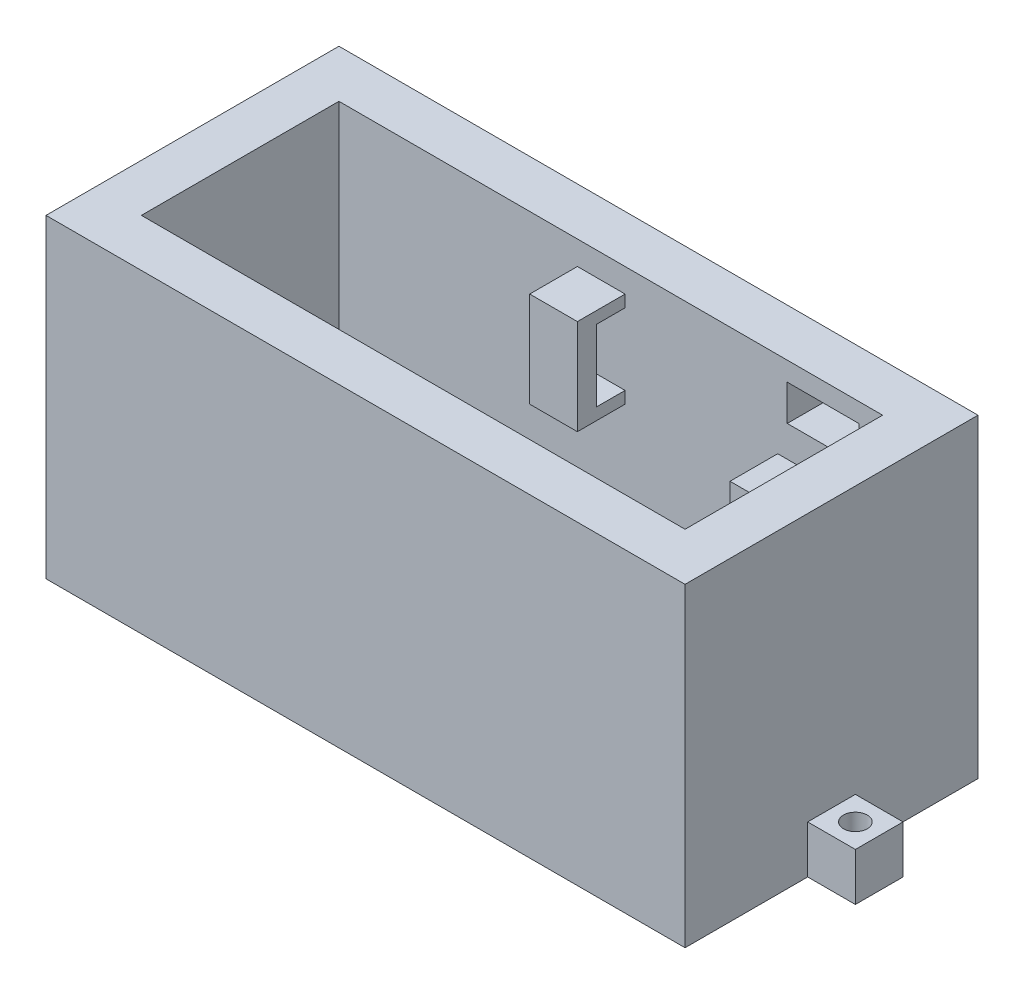
from build123d import *

# Parameters (mm, degrees)
SKETCH1_W                 = 72.39
SKETCH1_H                 = 26.30542054
BOSS_EXTRUDE1_DEPTH       = 35.56
SKETCH1_3_W               = 85.09
SKETCH1_3_H               = 39.00542054
SKETCH1_3_R               = 1.967283446
SKETCH1_3_W_2             = 3.175
SKETCH1_3_H_2             = 3.175
SKETCH1_3_R_2             = 1.397
BOSS_EXTRUDE2_DEPTH       = 6.35
SKETCH1_4_W               = 6.35
SKETCH1_4_H               = 6.35
SKETCH1_4_R               = 1.5875
BOSS_EXTRUDE3_DEPTH       = 6.35
SKETCH1_5_R               = 1.967283446
BOSS_EXTRUDE4_DEPTH       = 2.54
SKETCH2_W                 = 6.35
SKETCH2_H                 = 12.7
BOSS_EXTRUDE8_DEPTH       = 6.35
SKETCH2_4_W               = 6.35
SKETCH2_4_H               = 9.525
CUT_EXTRUDE1_DEPTH        = 3.81
SKETCH1_10_R              = 1.905
SKETCH1_10_R_2            = 1.397
SKETCH1_10_R_3            = 1.967283446
CUT_EXTRUDE4_DEPTH        = 98.832500687
BOSS_EXTRUDE11_DEPTH      = 2.54
BOSS_EXTRUDE11_DEPTH_BACK = 6.35
SKETCH1_11_W              = 3.175
SKETCH1_11_H              = 3.175
SKETCH6_W                 = 6.35
SKETCH6_H                 = 12.7
BOSS_EXTRUDE12_DEPTH      = 6.35
SKETCH6_8_W               = 6.35
SKETCH6_8_H               = 9.525
CUT_EXTRUDE5_DEPTH        = 3.81
SKETCH8_W                 = 9.525
SKETCH8_H                 = 4.7625
CUT_EXTRUDE6_DEPTH        = 18.542


with BuildPart() as part:
    # Sketch1 → Boss-Extrude1 (new body)
    with BuildSketch(Plane(origin=(0, 0, 0), x_dir=(1, 0, 0), z_dir=(0, 1, 0))):
        Polygon((78.74, 32.65542054), (-6.35, 32.65542054), (-6.35, 16.32771027), (-6.35, 9.97771027), (-6.35, -6.35), (78.74, -6.35), (78.74, 9.97771027), (78.74, 16.32771027), align=None)
        with Locations((36.195, 13.15271027)):
            Rectangle(SKETCH1_W, SKETCH1_H, mode=Mode.SUBTRACT)
    extrude(amount=BOSS_EXTRUDE1_DEPTH)

    # Sketch1_3 → Boss-Extrude2 (add)
    with BuildSketch(Plane(origin=(0, 0, 0), x_dir=(1, 0, 0), z_dir=(0, 1, 0))):
        with Locations((36.195, 13.15271027)):
            Rectangle(SKETCH1_3_W, SKETCH1_3_H)
        with Locations((6.985, 22.098)):
            Circle(SKETCH1_3_R, mode=Mode.SUBTRACT)
        with Locations((51.59375, 1.997278049)):
            Rectangle(SKETCH1_3_W_2, SKETCH1_3_H_2, mode=Mode.SUBTRACT)
        with Locations((61.595, 21.999778049)):
            Circle(SKETCH1_3_R_2, mode=Mode.SUBTRACT)
    extrude(amount=-BOSS_EXTRUDE2_DEPTH)

    # Sketch1_4 → Boss-Extrude3 (add)
    # profile 1 of 2: a face of its own
    with BuildSketch(Plane(origin=(0, 0, 0), x_dir=(1, 0, 0), z_dir=(0, 1, 0))):
        with Locations((-9.525, 13.15271027)):
            Rectangle(SKETCH1_4_W, SKETCH1_4_H)
        with Locations((-9.525, 13.15271027)):
            Circle(SKETCH1_4_R, mode=Mode.SUBTRACT)
    # profile 2 of 2: a face of its own
    with BuildSketch(Plane(origin=(0, 0, 0), x_dir=(1, 0, 0), z_dir=(0, 1, 0))):
        with Locations((81.915, 13.15271027)):
            Rectangle(SKETCH1_4_W, SKETCH1_4_H)
        with Locations((81.915, 13.15271027)):
            Circle(SKETCH1_4_R, mode=Mode.SUBTRACT)
    extrude(amount=-BOSS_EXTRUDE3_DEPTH)

    # Sketch1_5 → Boss-Extrude4 (add)
    with BuildSketch(Plane(origin=(0, 0, 0), x_dir=(1, 0, 0), z_dir=(0, 1, 0))):
        with Locations((6.985, 22.098)):
            Circle(SKETCH1_5_R)
    extrude(amount=-BOSS_EXTRUDE4_DEPTH)

    # Sketch2 → Boss-Extrude8 (add)
    with BuildSketch(Plane.XY.offset(-26.30542054)):
        with Locations((34.925, 26.035)):
            Rectangle(SKETCH2_W, SKETCH2_H)
    extrude(amount=BOSS_EXTRUDE8_DEPTH)

    # Sketch2_4 → Cut-Extrude1 (cut)
    with BuildSketch(Plane.XY.offset(-26.30542054)):
        with Locations((34.925, 26.035)):
            Rectangle(SKETCH2_4_W, SKETCH2_4_H)
    extrude(amount=CUT_EXTRUDE1_DEPTH, mode=Mode.SUBTRACT)

    # Sketch1_10 → Cut-Extrude4 (cut, through all)
    # profile 1 of 2: a face of its own
    with BuildSketch(Plane(origin=(0, 0, 0), x_dir=(1, 0, 0), z_dir=(0, 1, 0))):
        with Locations((61.595, 21.999778049)):
            Circle(SKETCH1_10_R)
        with Locations((61.595, 21.999778049)):
            Circle(SKETCH1_10_R_2, mode=Mode.SUBTRACT)
    # profile 2 of 2: a face of its own
    with BuildSketch(Plane(origin=(0, 0, 0), x_dir=(1, 0, 0), z_dir=(0, 1, 0))):
        with Locations((6.985, 22.098)):
            Circle(SKETCH1_10_R_3)
        with Locations((6.985, 22.098)):
            Circle(SKETCH1_10_R_2, mode=Mode.SUBTRACT)
    extrude(amount=-CUT_EXTRUDE4_DEPTH, mode=Mode.SUBTRACT)


with BuildPart() as cut_extrude4_piece_1:
    # of the separate pieces the step leaves, piece 1, a body of its own (cut_extrude4_pieces)
    add(part.part.solids().sort_by_distance((78.74, 35.56, -32.65542054))[0])

    # Sketch1_11 → Boss-Extrude11 (add, two sides: drawn at the far end of the back side and taken through both)
    with BuildSketch(Plane(origin=(0, 0, 0), x_dir=(1, 0, 0), z_dir=(0, 1, 0)).offset(-BOSS_EXTRUDE11_DEPTH_BACK)):
        with Locations((51.59375, 1.997278049)):
            Rectangle(SKETCH1_11_W, SKETCH1_11_H)
    extrude(amount=BOSS_EXTRUDE11_DEPTH + BOSS_EXTRUDE11_DEPTH_BACK)

    # Sketch6 → Boss-Extrude12 (add)
    with BuildSketch(Plane(origin=(72.39, 0, -72.39), x_dir=(0, 0, 1), z_dir=(-1, 0, 0))):
        with Locations((56.87957946, 25.4)):
            Rectangle(SKETCH6_W, SKETCH6_H)
    extrude(amount=BOSS_EXTRUDE12_DEPTH)

    # Sketch6_8 → Cut-Extrude5 (cut)
    with BuildSketch(Plane(origin=(72.39, 0, -72.39), x_dir=(0, 0, 1), z_dir=(-1, 0, 0))):
        with Locations((56.87957946, 25.4)):
            Rectangle(SKETCH6_8_W, SKETCH6_8_H)
    extrude(amount=CUT_EXTRUDE5_DEPTH, mode=Mode.SUBTRACT)

    # Sketch8 → Cut-Extrude6 (cut)
    with BuildSketch(Plane.XY.offset(-26.30542054)):
        with Locations((64.4525, 30.63875)):
            Rectangle(SKETCH8_W, SKETCH8_H)
    extrude(amount=-CUT_EXTRUDE6_DEPTH, mode=Mode.SUBTRACT)


with BuildPart() as cut_extrude4_piece_2:
    # of the separate pieces the step leaves, piece 2, a body of its own (cut_extrude4_pieces)
    add(part.part.solids().sort_by_distance((8.382, -2.54, -22.098))[0])


solid = cut_extrude4_piece_1.part
